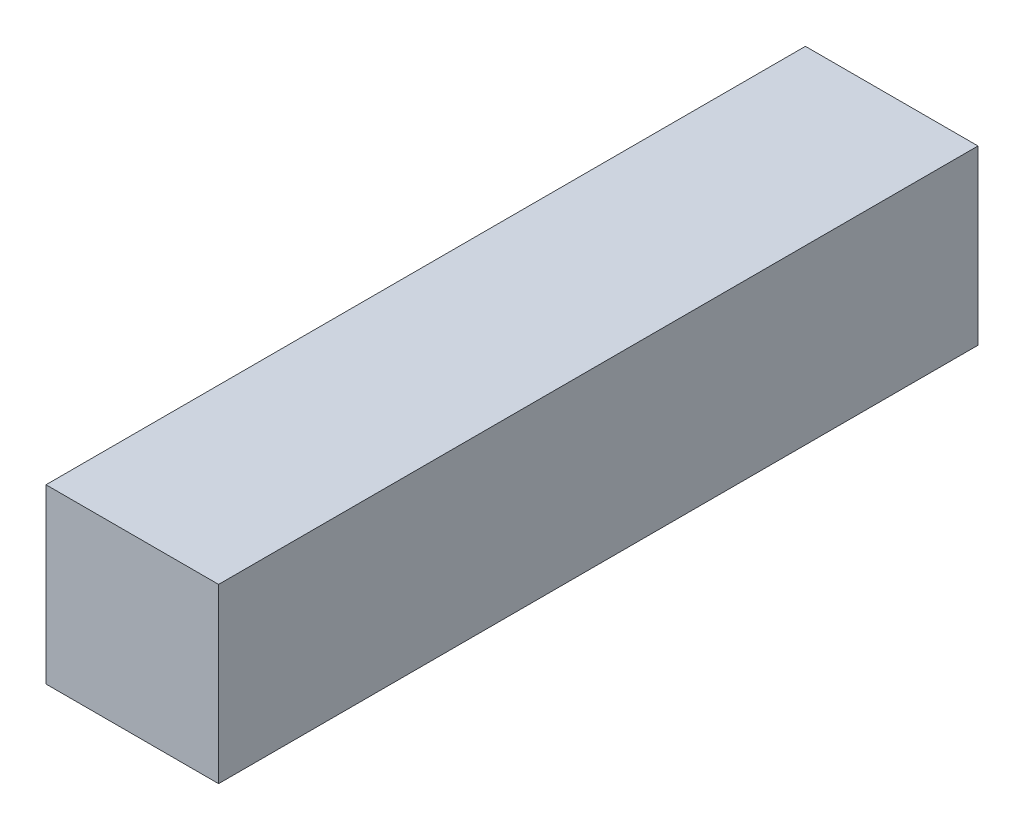
from build123d import *

# Parameters (mm, degrees)
SKETCH1_W           = 12.5
SKETCH1_H           = 12.5
BOSS_EXTRUDE1_DEPTH = 55


with BuildPart() as part:
    # Sketch1 → Boss-Extrude1 (new body)
    with BuildSketch(Plane.XY):
        with Locations((6.25, -6.25)):
            Rectangle(SKETCH1_W, SKETCH1_H)
    extrude(amount=BOSS_EXTRUDE1_DEPTH)


solid = part.part
